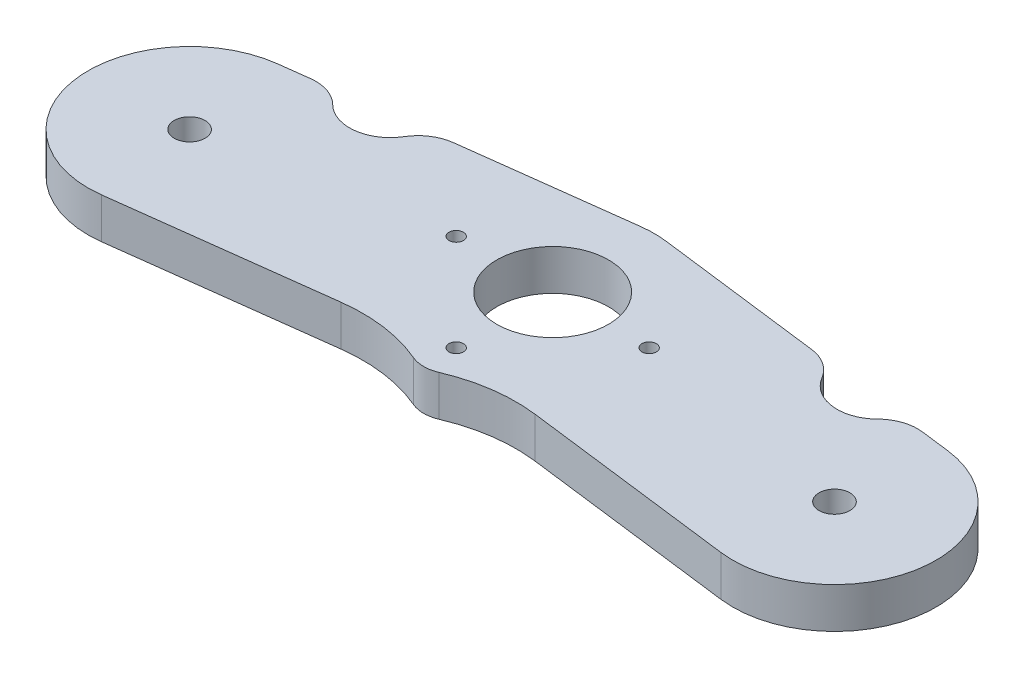
from build123d import *

# Parameters (mm, degrees)
SKETCH1_R              = 5.08
BOSS_EXTRUDE1_DEPTH    = 6.35
F_10_32_TAPPED_HOLE1_D = 4.826
SKETCH7_R              = 8.73125
CUT_EXTRUDE1_DEPTH     = 7.35
SKETCH8_R              = 6.35
CUT_EXTRUDE2_DEPTH     = 7.35
FILLET1_R              = 25.4
FILLET2_R              = 6.35
F_4_40_TAPPED_HOLE1_D  = 2.2606


with BuildPart() as part:
    # Sketch1 → Boss-Extrude1 (new body)
    with BuildSketch(Plane(origin=(0, 0, 0), x_dir=(1, 0, 0), z_dir=(0, 1, 0))):
        with Locations((0, -15.08125)):
            Circle(SKETCH1_R)
        with BuildLine():
            Line((1.984375, -15.750488274), (-48.417187476, -22.100488274))
            ThreePointArc((-48.417187476, -22.100488274), (-66.152050749, -8.334375), (-52.385937476, 9.400488274))
            Line((-52.385937476, 9.400488274), (-1.984375, 15.750488274))
            ThreePointArc((-1.984375, 15.750488274), (15.750488274, 1.984375), (1.984375, -15.750488274))
        make_face()
        with BuildLine():
            Line((1.984375, 15.750488274), (52.385937476, 9.400488274))
            ThreePointArc((52.385937476, 9.400488274), (66.152050749, -8.334375), (48.417187476, -22.100488274))
            Line((48.417187476, -22.100488274), (-1.984375, -15.750488274))
            ThreePointArc((-1.984375, -15.750488274), (-15.750488274, 1.984375), (1.984375, 15.750488274))
        make_face()
    extrude(amount=BOSS_EXTRUDE1_DEPTH)

    # #10-32 Tapped Hole1 (through all)
    with Locations(Plane(origin=(0, 6.35, 0), x_dir=(1, 0, 0), z_dir=(0, 1, 0))):
        with Locations((-50.401562476, -6.35), (50.401562476, -6.35)):
            Hole(F_10_32_TAPPED_HOLE1_D / 2)

    # Sketch7 → Cut-Extrude1 (cut, through all)
    with BuildSketch(Plane(origin=(0, 6.35, 0), x_dir=(1, 0, 0), z_dir=(0, 1, 0))):
        Circle(SKETCH7_R)
    extrude(amount=-CUT_EXTRUDE1_DEPTH, mode=Mode.SUBTRACT)

    # Sketch8 → Cut-Extrude2 (cut, through all)
    with BuildSketch(Plane(origin=(0, 6.35, 0), x_dir=(1, 0, 0), z_dir=(0, 1, 0))):
        with Locations((-38.1, 12.7)):
            Circle(SKETCH8_R)
        with Locations((38.1, 12.7)):
            Circle(SKETCH8_R)
    extrude(amount=-CUT_EXTRUDE2_DEPTH, mode=Mode.SUBTRACT)

    # Fillet1
    fillet1_edges = [part.edges().sort_by_distance(p)[0] for p in [
        (-4.844257487, 3.175, 16.6108151),
        (4.844257487, 3.175, 16.6108151),
    ]]
    fillet(fillet1_edges, radius=FILLET1_R)

    # Fillet2
    fillet2_edges = [part.edges().sort_by_distance(p)[0] for p in [
        (-31.789208912, 3.175, -11.995432159),
        (-44.038818433, 3.175, -10.452126424),
        (31.789208912, 3.175, -11.995432159),
        (44.038818433, 3.175, -10.452126424),
    ]]
    fillet(fillet2_edges, radius=FILLET2_R)

    # #4-40 Tapped Hole1 (through all)
    with Locations(Plane(origin=(0, 6.35, 0), x_dir=(1, 0, 0), z_dir=(0, 1, 0))):
        with Locations((-15.08125, 0), (15.08125, 0), (0, -15.08125)):
            Hole(F_4_40_TAPPED_HOLE1_D / 2)


solid = part.part
